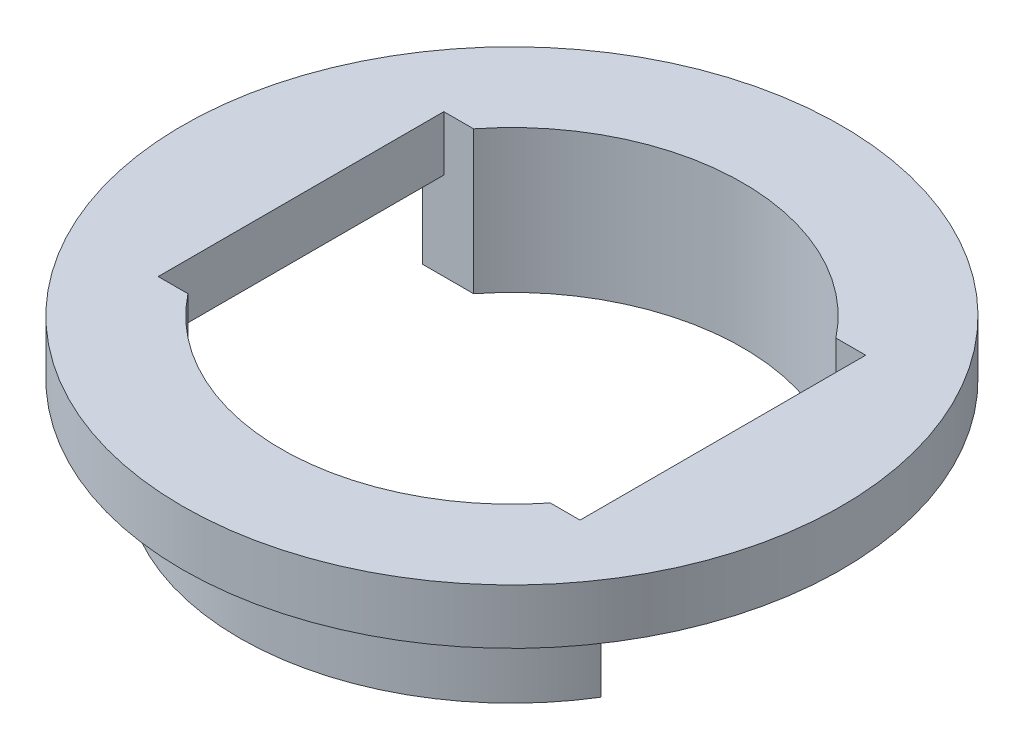
from build123d import *
from build123d.topology import SkipClean

# Parameters (mm, degrees)
SKETCH1_R               = 15
SKETCH1_W               = 19.2
SKETCH1_H               = 13
BOSS_EXTRUDE1_DEPTH     = 2.5
BOSS_EXTRUDE2_DEPTH     = 4
CUT_EXTRUDE1_DEPTH      = 22.587033145
CUT_EXTRUDE1_DEPTH_BACK = 22.587033145


with BuildPart() as part:
    # Sketch1 → Boss-Extrude1 (new body)
    with BuildSketch(Plane(origin=(0, 0, 0), x_dir=(1, 0, 0), z_dir=(0, 1, 0))):
        Circle(SKETCH1_R)
        Rectangle(SKETCH1_W, SKETCH1_H, mode=Mode.SUBTRACT)
    extrude(amount=BOSS_EXTRUDE1_DEPTH)

    # Sketch2 → Boss-Extrude2 (add)
    with BuildSketch(Plane.XZ):
        with BuildLine():
            ThreePointArc((10.559829544, 6.5), (0, 12.4), (-10.559829544, 6.5))
            Line((-10.559829544, 6.5), (-8.246211251, 6.5))
            ThreePointArc((-8.246211251, 6.5), (0, 10.5), (8.246211251, 6.5))
            Line((8.246211251, 6.5), (10.559829544, 6.5))
        make_face()
        with BuildLine():
            Line((-8.246211251, -6.5), (-10.559829544, -6.5))
            ThreePointArc((-10.559829544, -6.5), (0, -12.4), (10.559829544, -6.5))
            Line((10.559829544, -6.5), (8.246211251, -6.5))
            ThreePointArc((8.246211251, -6.5), (0, -10.5), (-8.246211251, -6.5))
        make_face()
    extrude(amount=BOSS_EXTRUDE2_DEPTH)

    # Sketch2_3 → Cut-Extrude1 (cut, two sides: drawn at the far end of the back side and taken through both)
    with SkipClean():  # the faces are left unmerged after this step: merging them gives an invalid solid
        with BuildSketch(Plane.XZ.offset(-CUT_EXTRUDE1_DEPTH_BACK)):
            with BuildLine():
                ThreePointArc((8.246211251, 6.5), (0, 10.5), (-8.246211251, 6.5))
                Line((-8.246211251, 6.5), (8.246211251, 6.5))
            make_face()
            with BuildLine():
                Line((8.246211251, -6.5), (-8.246211251, -6.5))
                ThreePointArc((-8.246211251, -6.5), (0, -10.5), (8.246211251, -6.5))
            make_face()
        extrude(amount=CUT_EXTRUDE1_DEPTH + CUT_EXTRUDE1_DEPTH_BACK, mode=Mode.SUBTRACT)


solid = part.part
